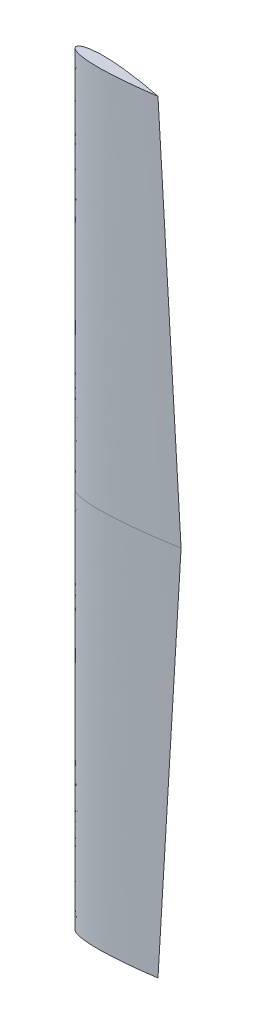
from build123d import *


with BuildPart() as part:
    # rootSketch → Loft1 section 0
    with BuildSketch(Plane(origin=(0, 0, 0), x_dir=(1, 0, 0), z_dir=(0, 1, 0))):
        with BuildLine():
            add(Edge.make_bspline(
                [(0, 0), (-0.000175064, 0.598414419), (0.05674218, 1.565666705), (0.275775876, 2.964091734), (0.822569463, 4.783047556), (1.555439608, 6.471754067), (2.628644933, 8.313158319), (4.149953111, 10.339392549), (6.337536022, 12.643904837), (9.58083252, 15.355757519), (14.495457526, 18.593370314), (21.981477178, 22.413652887), (33.589797591, 26.886946537), (51.014579668, 31.717007882), (76.952534748, 36.521841199), (110.407088273, 39.985836425), (144.144234157, 41.345693361), (175.979765102, 41.341164519), (207.800761075, 40.520831926), (234.298096736, 39.25088481), (260.767230587, 37.510714556), (287.206944997, 35.37680477), (308.340510089, 33.459919147), (329.456088108, 31.353710721), (350.553689705, 29.075271999), (368.998458414, 26.942061245), (384.797125332, 25.019930558), (397.95503649, 23.357640829), (408.476988762, 21.992088906), (421.623198519, 20.241108533), (437.38998035, 18.06970481), (455.76892534, 15.434711532), (476.754832722, 12.280961423), (495.094583008, 9.393753263), (509.495031881, 7.036344093), (519.952902261, 5.27635633), (525.845799056, 4.268584971), (529.742495971, 3.595795898), (533.062680296, 3.017336431), (535.545940255, 2.58322589), (539.115610217, 1.952521224), (542.392994029, 1.372884855), (546.49133396, 0.635531428), (548.812711406, 0.215715496), (550, 0)],
                knots=[0, 0, 0, 0, 0, 0.003840944, 0.006235023, 0.009072291, 0.01219322, 0.015656839, 0.019917177, 0.025338962, 0.032592504, 0.042799388, 0.05770457, 0.079310668, 0.112503101, 0.158972616, 0.227236465, 0.295500326, 0.329632258, 0.36376419, 0.432028053, 0.466159984, 0.500291915, 0.534423847, 0.56855578, 0.602687711, 0.636819643, 0.653885609, 0.670951575, 0.688017542, 0.705083508, 0.739215439, 0.773347371, 0.807479302, 0.841611234, 0.8586772, 0.867210184, 0.875743167, 0.880009658, 0.88427615, 0.888542642, 0.892809133, 0.901342117, 0.9098751, 0.9098751, 0.9098751, 0.9098751, 0.9098751], degree=4))
            add(Edge.make_bspline(
                [(0, 0), (-0.000175064, -0.598414419), (0.05674218, -1.565666705), (0.275775876, -2.964091734), (0.822569463, -4.783047556), (1.555439608, -6.471754067), (2.628644933, -8.313158319), (4.149953111, -10.339392549), (6.337536022, -12.643904837), (9.58083252, -15.355757519), (14.495457526, -18.593370314), (21.981477178, -22.413652887), (33.589797591, -26.886946537), (51.014579668, -31.717007882), (76.952534748, -36.521841199), (110.407088273, -39.985836425), (144.144234157, -41.345693361), (175.979765102, -41.341164519), (207.800761075, -40.520831926), (234.298096736, -39.25088481), (260.767230587, -37.510714556), (287.206944997, -35.37680477), (308.340510089, -33.459919147), (329.456088108, -31.353710721), (350.553689705, -29.075271999), (368.998458414, -26.942061245), (384.797125332, -25.019930558), (397.95503649, -23.357640829), (408.476988762, -21.992088906), (421.623198519, -20.241108533), (437.38998035, -18.06970481), (455.76892534, -15.434711532), (476.754832722, -12.280961423), (495.094583008, -9.393753263), (509.495031881, -7.036344093), (519.952902261, -5.27635633), (525.845799056, -4.268584971), (529.742495971, -3.595795898), (533.062680296, -3.017336431), (535.545940255, -2.58322589), (539.115610217, -1.952521224), (542.392994029, -1.372884855), (546.49133396, -0.635531428), (548.812711406, -0.215715496), (550, 0)],
                knots=[0, 0, 0, 0, 0, 0.003840944, 0.006235023, 0.009072291, 0.01219322, 0.015656839, 0.019917177, 0.025338962, 0.032592504, 0.042799388, 0.05770457, 0.079310668, 0.112503101, 0.158972616, 0.227236465, 0.295500326, 0.329632258, 0.36376419, 0.432028053, 0.466159984, 0.500291915, 0.534423847, 0.56855578, 0.602687711, 0.636819643, 0.653885609, 0.670951575, 0.688017542, 0.705083508, 0.739215439, 0.773347371, 0.807479302, 0.841611234, 0.8586772, 0.867210184, 0.875743167, 0.880009658, 0.88427615, 0.888542642, 0.892809133, 0.901342117, 0.9098751, 0.9098751, 0.9098751, 0.9098751, 0.9098751], degree=4))
        make_face()
    # tipSketch → Loft1 section 1
    with BuildSketch(Plane(origin=(0, 1999.998, 0), x_dir=(1, 0, 0), z_dir=(0, 1, 0))):
        with BuildLine():
            add(Edge.make_bspline(
                [(0, 0), (-0.000228899, 0.479858813), (0.04564675, 1.255758568), (0.221286007, 2.369515366), (0.657859126, 3.807369511), (1.241502178, 5.13939147), (2.093218808, 6.583027149), (3.298914243, 8.163161741), (5.027562614, 9.946687533), (7.571949858, 12.022421318), (11.447749672, 14.499750429), (17.374572049, 17.401208883), (26.574579565, 20.743677375), (40.386686858, 24.258671538), (61.063223567, 27.613700645), (87.800360237, 29.748176945), (119.076321904, 30.250390351), (148.906909434, 29.269595165), (174.434446657, 27.677061275), (195.677173308, 25.939701393), (212.6521066, 24.336142386), (229.608147224, 22.543185115), (246.545559682, 20.582463832), (263.464534024, 18.47051028), (280.366199386, 16.221007081), (295.139101355, 14.141555824), (307.792116436, 12.284287592), (318.327001948, 10.688793047), (326.754082575, 9.383266749), (337.274866736, 7.717820024), (349.904558573, 5.660712181), (364.602195307, 3.184599276), (381.418219444, 0.234116982), (396.06088703, -2.438399607), (408.678523167, -4.82205648), (419.053303631, -6.834679209), (426.540766916, -8.319994598), (432.488289171, -9.517971541), (437.136393407, -10.470026519), (439.050865014, -10.864429743), (440, -11.060735094)],
                knots=[0, 0, 0, 0, 0, 0.003845658, 0.006245277, 0.009022611, 0.012044555, 0.015501019, 0.019679599, 0.024953702, 0.03195376, 0.041823539, 0.056555515, 0.077861291, 0.110456483, 0.156156733, 0.224644526, 0.293132328, 0.361620133, 0.395864036, 0.43010794, 0.464351842, 0.498595745, 0.532839648, 0.567083551, 0.601327453, 0.635571356, 0.652693307, 0.669815259, 0.68693721, 0.704059162, 0.738303064, 0.772546967, 0.806790869, 0.841034772, 0.858156724, 0.875278677, 0.892400629, 0.900961606, 0.909522582, 0.909522582, 0.909522582, 0.909522582, 0.909522582], degree=4))
            add(Edge.make_bspline(
                [(0, 0), (-0.024338788, -0.47924123), (-0.017505637, -1.25646598), (0.101951829, -2.37764093), (0.465729536, -3.835614322), (0.981708887, -5.195278626), (1.759815271, -6.679884851), (2.884595075, -8.318603011), (4.521448051, -10.18673089), (6.958327794, -12.387683936), (10.704760594, -15.056620992), (16.478315334, -18.252203927), (25.498762791, -22.052698842), (39.116816309, -26.257233328), (59.598666505, -30.646903377), (86.194787704, -34.122072943), (117.406013104, -36.1950914), (147.248202694, -36.714352533), (172.823513308, -36.406443785), (194.126701937, -35.738604581), (211.16076488, -34.989964887), (228.185475205, -34.0512169), (245.20001008, -32.943980833), (262.203728689, -31.6847771), (279.197071269, -30.287327774), (294.055795032, -28.952757341), (306.786145982, -27.733577035), (317.387890012, -26.669415808), (325.869922149, -25.788951368), (336.461097339, -24.654217801), (349.178195308, -23.23427843), (363.981678893, -21.499765699), (380.924708633, -19.39791966), (395.683160669, -17.464489425), (408.404625398, -15.717807738), (418.867424921, -14.229000809), (426.420059874, -13.121763926), (432.420261685, -12.224129281), (437.110330517, -11.506817617), (439.042200585, -11.209103862), (440, -11.060735094)],
                knots=[0, 0, 0, 0, 0, 0.003845658, 0.006245277, 0.009022611, 0.012044555, 0.015501019, 0.019679599, 0.024953702, 0.03195376, 0.041823539, 0.056555515, 0.077861291, 0.110456483, 0.156156733, 0.224644526, 0.293132328, 0.361620133, 0.395864036, 0.43010794, 0.464351842, 0.498595745, 0.532839648, 0.567083551, 0.601327453, 0.635571356, 0.652693307, 0.669815259, 0.68693721, 0.704059162, 0.738303064, 0.772546967, 0.806790869, 0.841034772, 0.858156724, 0.875278677, 0.892400629, 0.900961606, 0.909522582, 0.909522582, 0.909522582, 0.909522582, 0.909522582], degree=4))
        make_face()
    loft1 = loft()

    # Mirror1: Loft1 across plane
    add(loft1.mirror(Plane.ZX))


solid = part.part
